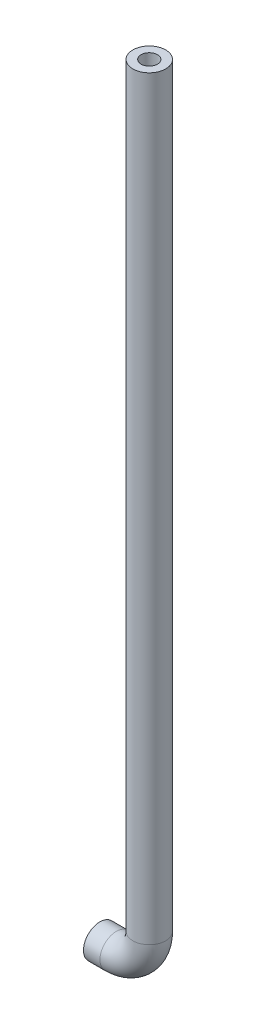
from build123d import *

# Parameters (mm, degrees)
SWEEP1_PROFILE_R = 12.7
SHELL2_T         = -6.35


with BuildPart() as part:
    # Sweep1: sweep along a path in Sketch1
    with BuildLine(Plane.XY) as sweep1_path:
        Line((38.1, 608.33), (38.1, 25.4))
        ThreePointArc((38.1, 25.4), (30.660512242, 7.439487758), (12.7, 0))
        Line((12.7, 0), (0, 0))
    # Sweep1 profile (on start of the path) → Sweep1 (sweep)
    with BuildSketch(Plane(origin=(38.1, 608.33, 0), x_dir=(-1, 0, 0), z_dir=(0, -1, 0))):
        Circle(SWEEP1_PROFILE_R)
    sweep(path=sweep1_path.line)

    # Shell2
    shell2_openings = [part.faces().sort_by_distance(p)[0] for p in [
        (0, 12.7, 0),
        (25.4, 608.33, 0),
    ]]
    offset(amount=SHELL2_T, openings=shell2_openings, kind=Kind.INTERSECTION)


solid = part.part
